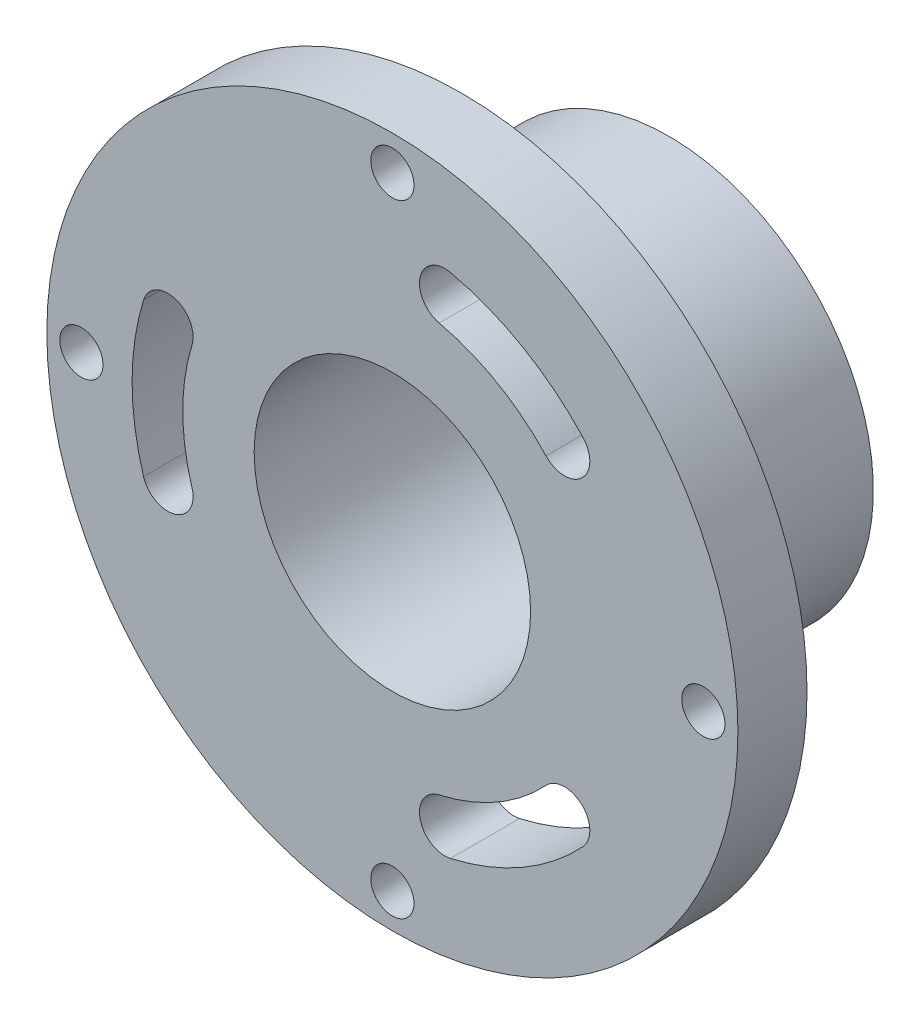
from build123d import *

# Parameters (mm, degrees)
SKETCH1_R                       = 31.75
BOSS_EXTRUDE1_DEPTH             = 25.4
SKETCH2_OUTSIDE_W               = 84.166
SKETCH2_OUTSIDE_H               = 84.166
SKETCH2_OUTSIDE_R               = 18.796
CUT_EXTRUDE1_DEPTH              = 19.05
SKETCH3_R                       = 12.7
CUT_EXTRUDE2_DEPTH              = 26.4
F_2_56_TAPPED_HOLE1_D           = 1.778
F_2_56_TAPPED_HOLE1_DEPTH       = 5.73278
F_2_56_TAPPED_HOLE1_TIP         = 0.53416509
F_5_32_0_15625_DIAMETER_HOLE1_D = 3.96875
MIRROR2_COPY_1_D                = 3.96875
MIRROR2_COPY_2_D                = 3.96875
CUT_EXTRUDE3_DEPTH              = 26.4
CIRPATTERN1_COUNT               = 3
SKETCH10_R                      = 10.16
SKETCH10_R_2                    = 7.9375
CUT_EXTRUDE4_DEPTH              = 3.175


with BuildPart() as part:
    # Sketch1 → Boss-Extrude1 (new body)
    with BuildSketch(Plane.XY):
        Circle(SKETCH1_R)
    extrude(amount=BOSS_EXTRUDE1_DEPTH)

    # Sketch2 outside → Cut-Extrude1 (cut)
    with BuildSketch(Plane(origin=(0, 0, 0), x_dir=(-1, 0, 0), z_dir=(0, 0, -1))):
        Rectangle(SKETCH2_OUTSIDE_W, SKETCH2_OUTSIDE_H)
        Circle(SKETCH2_OUTSIDE_R, mode=Mode.SUBTRACT)
    extrude(amount=-CUT_EXTRUDE1_DEPTH, mode=Mode.SUBTRACT)

    # Sketch3 → Cut-Extrude2 (cut, through all)
    with BuildSketch(Plane(origin=(0, 0, 0), x_dir=(-1, 0, 0), z_dir=(0, 0, -1))):
        Circle(SKETCH3_R)
    extrude(amount=-CUT_EXTRUDE2_DEPTH, mode=Mode.SUBTRACT)

    # #2-56 Tapped Hole1
    with Locations(Plane(origin=(0, 0, 0), x_dir=(-1, 0, 0), z_dir=(0, 0, -1))):
        with Locations((0, 15.24), (0, -15.24)):
            Hole(F_2_56_TAPPED_HOLE1_D / 2, depth=F_2_56_TAPPED_HOLE1_DEPTH)
            with Locations((0, 0, -(F_2_56_TAPPED_HOLE1_DEPTH + F_2_56_TAPPED_HOLE1_TIP / 2))):  # 118° drill point
                Cone(0, F_2_56_TAPPED_HOLE1_D / 2, F_2_56_TAPPED_HOLE1_TIP, mode=Mode.SUBTRACT)

    # 5/32 (0.15625) Diameter Hole1 (through all)
    with Locations(Plane.XY.offset(25.4)):
        with Locations((0, 28.575), (28.575, 0)):
            f_5_32_0_15625_diameter_hole1 = Hole(F_5_32_0_15625_DIAMETER_HOLE1_D / 2)

    # Mirror1: 5/32 (0.15625) Diameter Hole1 across plane
    add(f_5_32_0_15625_diameter_hole1.mirror(Plane.ZX), mode=Mode.SUBTRACT)

    # Mirror2 copy 1 (through all)
    with Locations(Plane(origin=(0, 0, 25.4), x_dir=(-1, 0, 0), z_dir=(0, 0, 1))):
        with Locations((0, 28.575), (28.575, 0)):
            Hole(MIRROR2_COPY_1_D / 2)

    # Mirror2 copy 2 (through all)
    with Locations(Plane(origin=(0, 0, 25.4), x_dir=(-1, 0, 0), z_dir=(0, 0, 1))):
        with Locations((0, -28.575), (28.575, 0)):
            Hole(MIRROR2_COPY_2_D / 2)

    # Sketch9 → Cut-Extrude3 (cut, through all)
    with BuildSketch(Plane.XY.offset(25.4)):
        with BuildLine():
            ThreePointArc((17.520714904, 16.278611836), (11.957933079, 20.711747646), (5.337333936, 23.312690118))
            ThreePointArc((5.337333936, 23.312690118), (2.551061387, 21.564550521), (4.299200984, 18.778277972))
            ThreePointArc((4.299200984, 18.778277972), (9.632066921, 16.683229289), (14.112865271, 13.112356254))
            ThreePointArc((14.112865271, 13.112356254), (17.399917879, 12.991559228), (17.520714904, 16.278611836))
        make_face()
    cut_extrude3 = extrude(amount=-CUT_EXTRUDE3_DEPTH, mode=Mode.SUBTRACT)

    # CirPattern1: Cut-Extrude3 ×3 about axis
    cirpattern1_axis = Axis((0, 0, 0), (0, 0, 1))
    for i in range(1, CIRPATTERN1_COUNT):
        add(cut_extrude3.rotate(cirpattern1_axis, i * 360 / CIRPATTERN1_COUNT), mode=Mode.SUBTRACT)

    # Sketch10 → Cut-Extrude4 (cut)
    with BuildSketch(Plane(origin=(0, 0, 0), x_dir=(-1, 0, 0), z_dir=(0, 0, -1))):
        Circle(SKETCH10_R)
        Circle(SKETCH10_R_2, mode=Mode.SUBTRACT)
    extrude(amount=-CUT_EXTRUDE4_DEPTH, mode=Mode.SUBTRACT)


solid = part.part
